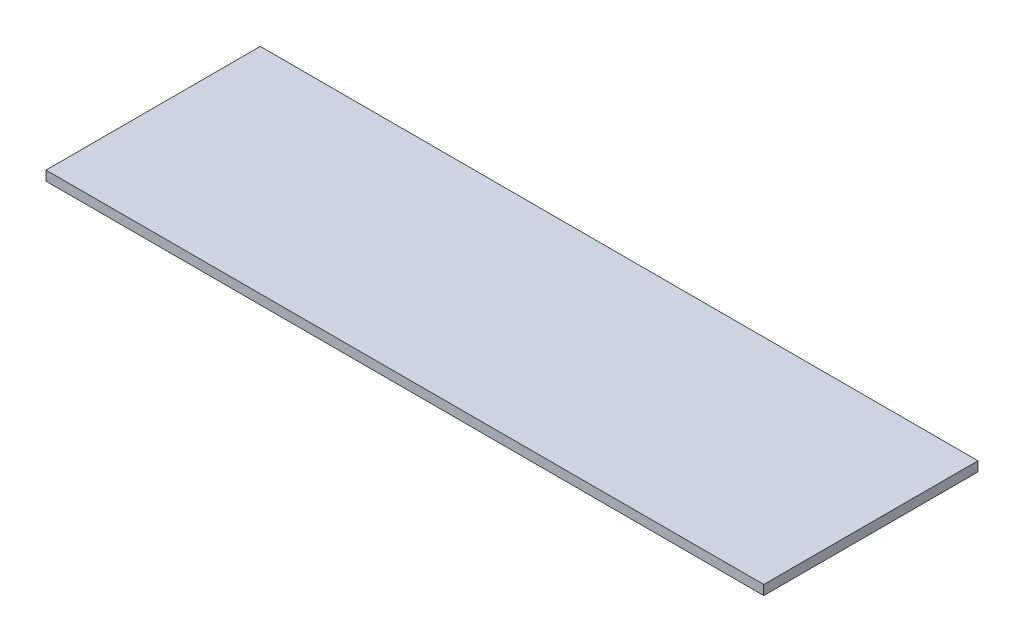
from build123d import *

# Parameters (mm, degrees)
SKETCH1_W           = 1340
SKETCH1_H           = 400
BOSS_EXTRUDE1_DEPTH = 18


with BuildPart() as part:
    # Sketch1 → Boss-Extrude1 (new body)
    with BuildSketch(Plane(origin=(0, 0, 0), x_dir=(1, 0, 0), z_dir=(0, 1, 0))):
        with Locations((670, 200)):
            Rectangle(SKETCH1_W, SKETCH1_H)
    extrude(amount=BOSS_EXTRUDE1_DEPTH)


solid = part.part
